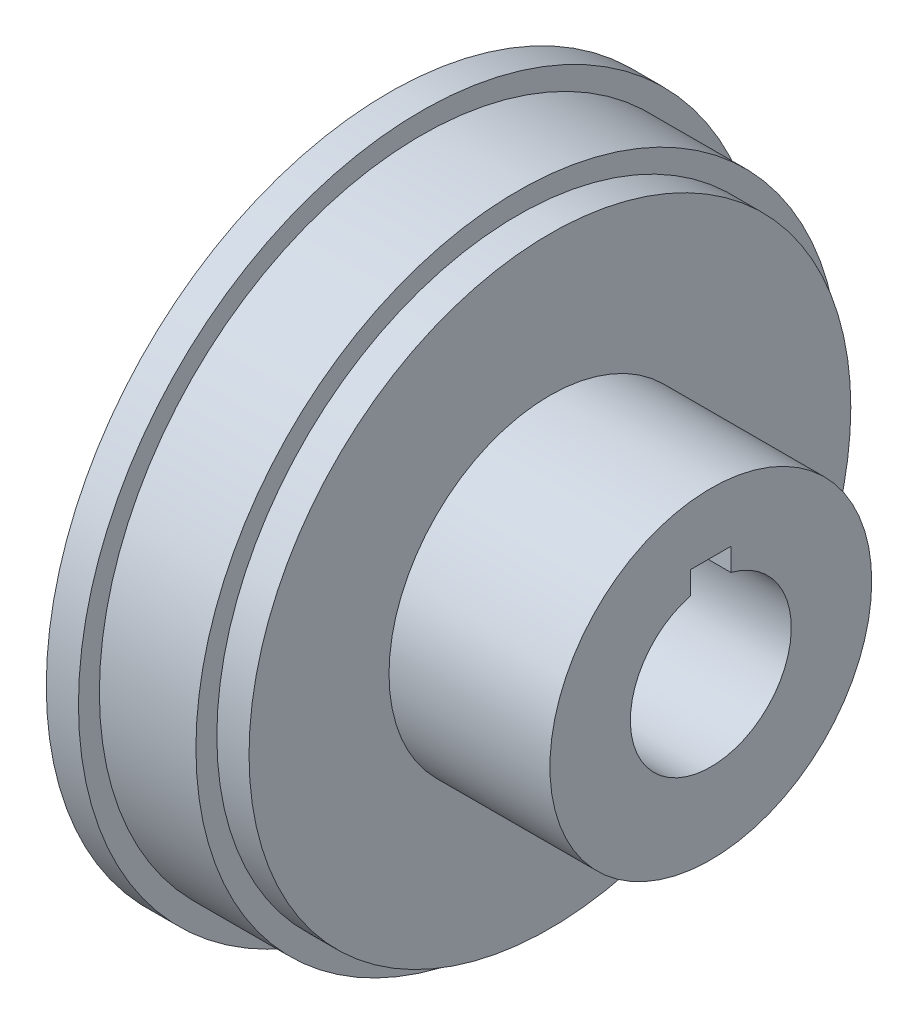
from build123d import *

# Parameters (mm, degrees)
SKETCH1_R           = 22.225
BOSS_EXTRUDE1_DEPTH = 25.4
SKETCH2_R           = 25.4
SKETCH2_R_2         = 10.9140625
BOSS_EXTRUDE2_DEPTH = 12.7
SKETCH3_R           = 25.4
SKETCH3_R_2         = 12.7
CUT_EXTRUDE1_DEPTH  = 12.7
SKETCH5_R           = 27.051
SKETCH5_R_2         = 25.4
BOSS_EXTRUDE3_DEPTH = 2.54
SKETCH6_R           = 25.4
SKETCH6_R_2         = 23.749
CUT_EXTRUDE3_DEPTH  = 2.54


with BuildPart() as part:
    # Sketch1 → Boss-Extrude1 (new body)
    with BuildSketch(Plane(origin=(0, 0, 0), x_dir=(0, 0, -1), z_dir=(1, 0, 0))):
        Circle(SKETCH1_R)
        with BuildLine():
            Line((-1.5875, 6.148361062), (-1.5875, 7.9375))
            Line((-1.5875, 7.9375), (1.5875, 7.9375))
            Line((1.5875, 7.9375), (1.5875, 6.148361062))
            ThreePointArc((1.5875, 6.148361062), (5.020115786, 3.888564967), (6.35, 0))
            ThreePointArc((6.35, 0), (-3.888564967, -5.020115786), (-1.5875, 6.148361062))
        make_face(mode=Mode.SUBTRACT)
    extrude(amount=BOSS_EXTRUDE1_DEPTH)

    # Sketch2 → Boss-Extrude2 (add)
    with BuildSketch(Plane.ZY):
        Circle(SKETCH2_R)
        Circle(SKETCH2_R_2, mode=Mode.SUBTRACT)
    extrude(amount=-BOSS_EXTRUDE2_DEPTH)

    # Sketch3 → Cut-Extrude1 (cut)
    with BuildSketch(Plane(origin=(25.4, 0, 0), x_dir=(0, 0, -1), z_dir=(1, 0, 0))):
        Circle(SKETCH3_R)
        Circle(SKETCH3_R_2, mode=Mode.SUBTRACT)
    extrude(amount=-CUT_EXTRUDE1_DEPTH, mode=Mode.SUBTRACT)

    # Sketch5 → Boss-Extrude3 (add)
    with BuildSketch(Plane.ZY):
        Circle(SKETCH5_R)
        Circle(SKETCH5_R_2, mode=Mode.SUBTRACT)
    extrude(amount=-BOSS_EXTRUDE3_DEPTH)

    # Sketch6 → Cut-Extrude3 (cut)
    with BuildSketch(Plane(origin=(12.7, 0, 0), x_dir=(0, 0, -1), z_dir=(1, 0, 0))):
        Circle(SKETCH6_R)
        Circle(SKETCH6_R_2, mode=Mode.SUBTRACT)
    extrude(amount=-CUT_EXTRUDE3_DEPTH, mode=Mode.SUBTRACT)


solid = part.part
